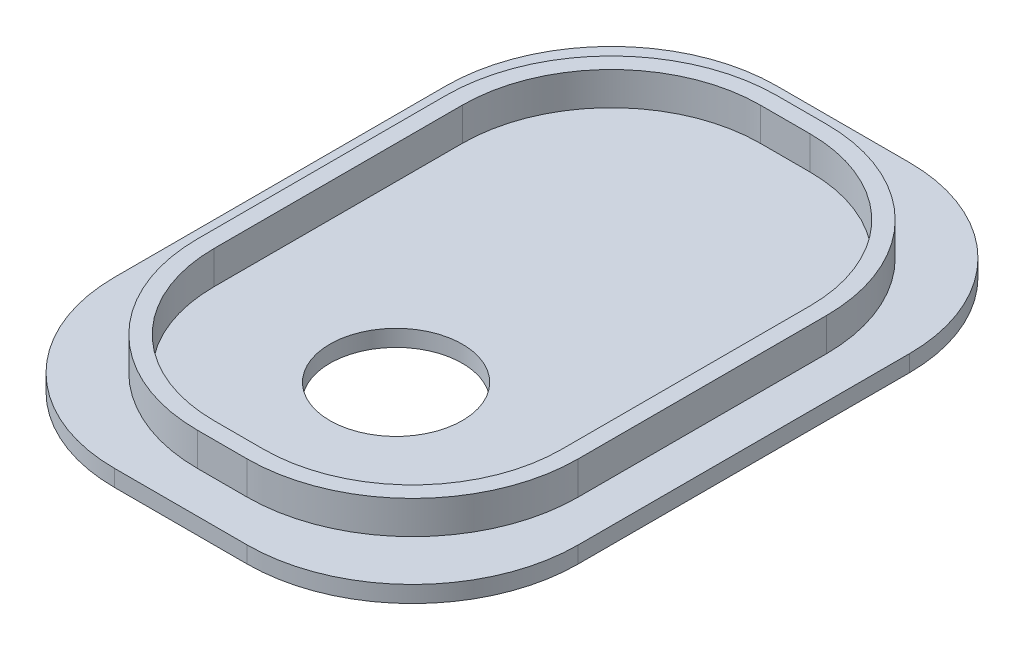
from build123d import *

# Parameters (mm, degrees)
BOSS_EXTRUDE1_DEPTH     = 2
BOSS_EXTRUDE3_DEPTH     = 1
CUT_EXTRUDE1_DEPTH      = 31.479501308
CUT_EXTRUDE1_DEPTH_BACK = 31.479501308
SKETCH2_R               = 4


with BuildPart() as part:
    # Sketch1 → Boss-Extrude1 (new body)
    with BuildSketch(Plane(origin=(0, 0, 0), x_dir=(1, 0, 0), z_dir=(0, 1, 0))):
        with BuildLine():
            ThreePointArc((-1.5, 24.5), (-8.571067812, 21.571067812), (-11.5, 14.5))
            Line((-11.5, 14.5), (-11.5, -0.5))
            ThreePointArc((-11.5, -0.5), (-8.571067812, -7.571067812), (-1.5, -10.5))
            Line((-1.5, -10.5), (1.5, -10.5))
            ThreePointArc((1.5, -10.5), (8.571067812, -7.571067812), (11.5, -0.5))
            Line((11.5, -0.5), (11.5, 14.5))
            ThreePointArc((11.5, 14.5), (8.571067812, 21.571067812), (1.5, 24.5))
            Line((1.5, 24.5), (-1.5, 24.5))
        make_face()
        with BuildLine():
            Line((-10.5, -0.5), (-10.5, 14.5))
            ThreePointArc((-10.5, 14.5), (-7.863961031, 20.863961031), (-1.5, 23.5))
            Line((-1.5, 23.5), (1.5, 23.5))
            ThreePointArc((1.5, 23.5), (7.863961031, 20.863961031), (10.5, 14.5))
            Line((10.5, 14.5), (10.5, -0.5))
            ThreePointArc((10.5, -0.5), (7.863961031, -6.863961031), (1.5, -9.5))
            Line((1.5, -9.5), (0, -9.5))
            Line((0, -9.5), (-1.5, -9.5))
            ThreePointArc((-1.5, -9.5), (-7.863961031, -6.863961031), (-10.5, -0.5))
        make_face(mode=Mode.SUBTRACT)
    extrude(amount=BOSS_EXTRUDE1_DEPTH)

    # Sketch1_4 → Boss-Extrude3 (add)
    with BuildSketch(Plane(origin=(0, 0, 0), x_dir=(1, 0, 0), z_dir=(0, 1, 0))):
        with BuildLine():
            ThreePointArc((14, 17), (11.071067812, 24.071067812), (4, 27))
            Line((4, 27), (-4, 27))
            ThreePointArc((-4, 27), (-11.071067812, 24.071067812), (-14, 17))
            Line((-14, 17), (-14, -3))
            ThreePointArc((-14, -3), (-11.071067812, -10.071067812), (-4, -13))
            Line((-4, -13), (4, -13))
            ThreePointArc((4, -13), (11.071067812, -10.071067812), (14, -3))
            Line((14, -3), (14, 17))
        make_face()
    extrude(amount=-BOSS_EXTRUDE3_DEPTH)

    # Sketch2 → Cut-Extrude1 (cut, two sides: drawn at the far end of the back side and taken through both)
    with BuildSketch(Plane(origin=(0, 0, 0), x_dir=(1, 0, 0), z_dir=(0, 1, 0)).offset(-CUT_EXTRUDE1_DEPTH_BACK)):
        Circle(SKETCH2_R)
    extrude(amount=CUT_EXTRUDE1_DEPTH + CUT_EXTRUDE1_DEPTH_BACK, mode=Mode.SUBTRACT)


solid = part.part
